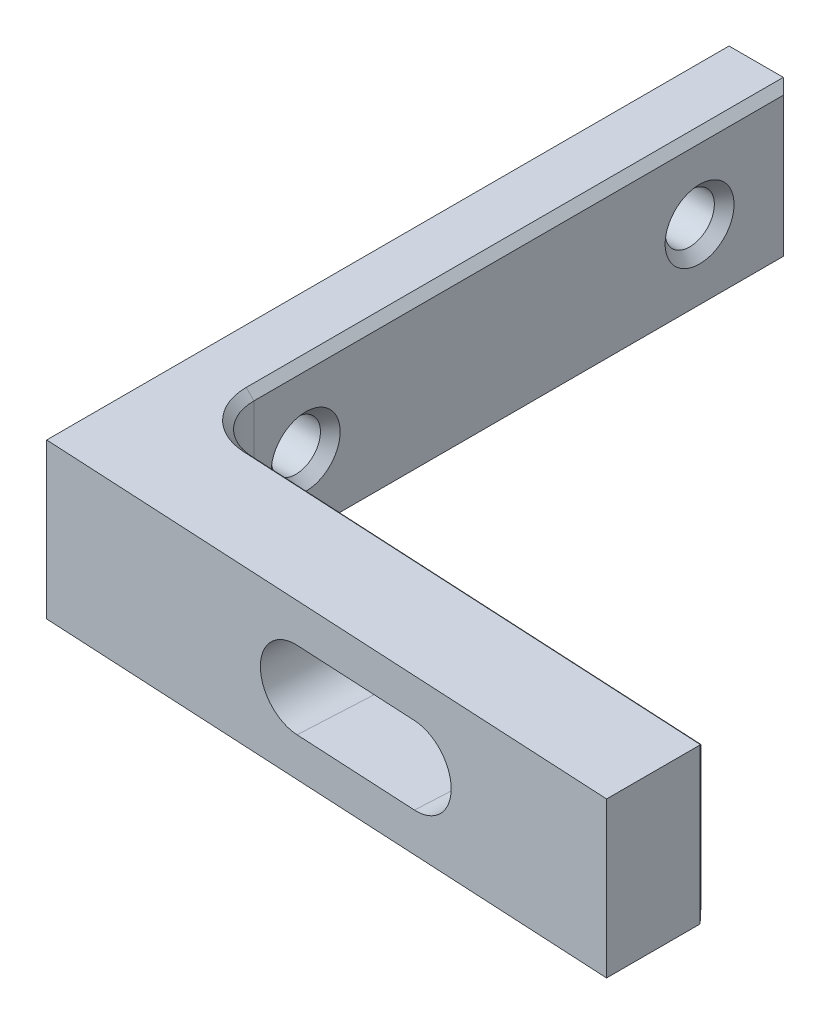
from build123d import *
from OCP.BRepFilletAPI import BRepFilletAPI_MakeChamfer

# Parameters (mm, degrees)
SKETCH1_W                             = 38.1
SKETCH1_H                             = 44
BOSS_EXTRUDE1_DEPTH                   = 10
CUT_EXTRUDE1_REACH                    = 32.772
SKETCH2_W                             = 34.1
SKETCH2_H                             = 37.65
F_1_8_0_125_DIAMETER_HOLE1_AT_2_COUNT = 2
F_1_8_0_125_DIAMETER_HOLE1_AT_2_PITCH = 25.4
DRAFT1_ANGLE                          = 3
CUT_EXTRUDE2_DEPTH                    = 33.229580472
CUT_EXTRUDE3_DEPTH                    = 45.389768844
FILLET2_R                             = 3.175
CHAMFER1_SIZE                         = 0.5
CHAMFER2_SIZE                         = 0.5
CHAMFER2_SIZE2                        = 0.528377251


with BuildPart() as part:
    # Sketch1 → Boss-Extrude1 (new body)
    with BuildSketch(Plane(origin=(0, 0, 0), x_dir=(1, 0, 0), z_dir=(0, 1, 0))):
        Rectangle(SKETCH1_W, SKETCH1_H)
    extrude(amount=BOSS_EXTRUDE1_DEPTH)

    # Sketch2 → Cut-Extrude1 (cut, up to next)
    with BuildSketch(Plane(origin=(0, 10, 0), x_dir=(1, 0, 0), z_dir=(0, 1, 0)), mode=Mode.PRIVATE) as cut_extrude1_sk1:
        with Locations((2, 3.175)):
            Rectangle(SKETCH2_W, SKETCH2_H)
    cut_extrude1_tool1 = extrude(cut_extrude1_sk1.sketch, amount=-CUT_EXTRUDE1_REACH, mode=Mode.PRIVATE) & part.part
    add(cut_extrude1_tool1.solids().sort_by_distance((2, 10, -3.175))[0], mode=Mode.SUBTRACT)

    # Sketch3 → 1/8 (0.125) Diameter Hole1 (revolve, cut)
    with BuildSketch(Plane(origin=(-19.05, 5, -16.1), x_dir=(0, 0, 1), z_dir=(0, 1, 0))):
        Polygon((0, 0), (0, 4), (2.2225, 4), (1.5875, 3.365), (1.5875, 0.635), (2.2225, 0), align=None)
    f_1_8_0_125_diameter_hole1 = revolve(axis=Axis((-25.4, 5, -16.1), (1, 0, 0)), mode=Mode.SUBTRACT)

    # 1/8 (0.125) Diameter Hole1 at 2: 1/8 (0.125) Diameter Hole1 ×2
    with Locations(*[(0, 0, i * F_1_8_0_125_DIAMETER_HOLE1_AT_2_PITCH) for i in range(1, F_1_8_0_125_DIAMETER_HOLE1_AT_2_COUNT)]):
        add(f_1_8_0_125_diameter_hole1, mode=Mode.SUBTRACT)

    # Draft1
    draft1_faces = [part.faces().sort_by_distance(p)[0] for p in [
        (0, 5, 22),
    ]]
    draft(draft1_faces, Plane(origin=(-19.05, 10, 22), x_dir=(0, 0, -1), z_dir=(-1, 0, 0)), DRAFT1_ANGLE)

    # Sketch7 → Cut-Extrude2 (cut, through all)
    with BuildSketch(Plane(origin=(0, 10, 0), x_dir=(1, 0, 0), z_dir=(0, 1, 0))):
        Polygon((-15.05, -15.65), (19.05, -15.65), (19.05, -17.437105274), align=None)
    extrude(amount=-CUT_EXTRUDE2_DEPTH, mode=Mode.SUBTRACT)

    # Sketch8 → Cut-Extrude3 (cut, through all)
    with BuildSketch(Plane(origin=(-0.859157962, 0, 16.393710517), x_dir=(-0.9986295347545739, 0, -0.05233595624294398), z_dir=(0.05233595624294399, 0, -0.998629534754574))):
        with BuildLine():
            Line((-7.189683217, 7.5), (0.810316783, 7.5))
            ThreePointArc((0.810316783, 7.5), (3.310316783, 5), (0.810316783, 2.5))
            Line((0.810316783, 2.5), (-7.189683217, 2.5))
            ThreePointArc((-7.189683217, 2.5), (-9.689683217, 5), (-7.189683217, 7.5))
        make_face()
    extrude(amount=-CUT_EXTRUDE3_DEPTH, mode=Mode.SUBTRACT)

    # Fillet2
    fillet2_edges = [part.edges().sort_by_distance(p)[0] for p in [
        (-15.05, 5, 15.65),
    ]]
    fillet(fillet2_edges, radius=FILLET2_R)

    # Chamfer1
    chamfer1_edges = [part.edges().sort_by_distance(p)[0] for p in [
        (8.817245881, 5, 16.900829354),
        (2.326153905, 2.5, 16.560645639),
        (-4.164938071, 5, 16.220461923),
        (2.326153905, 7.5, 16.560645639),
    ]]
    chamfer(chamfer1_edges, length=CHAMFER1_SIZE)

    # Chamfer2: one chamfer whose edges measure the first distance from different faces: ONE call of the kernel's chamfer builder (chamfer() names one face for all edges)
    chamfer2_edges_1 = [part.edges().sort_by_distance(p)[0] for p in [
        (-15.05, 0, -4.68148125),
        (-15.05, 5, -22),
        (-15.05, 10, -4.68148125),
        (3.504416669, 10, 16.622395774),
        (3.504416669, 0, 16.622395774),
        (-14.178063628, 10, 14.822563279),
        (-14.178063628, 0, 14.822563279),
    ]]
    chamfer2_edges_2 = [part.edges().sort_by_distance(p)[0] for p in [
        (19.05, 5, 17.437105274),
    ]]
    chamfer2_side_2 = [part.faces().sort_by_distance(p)[0] for p in [
        (9.643116423, 5, 16.944111395),
    ]]
    chamfer2 = BRepFilletAPI_MakeChamfer(part.part.solid().wrapped)
    for e in chamfer2_edges_1:
        chamfer2.Add(CHAMFER2_SIZE, e.wrapped)
    for e in chamfer2_edges_2:
        chamfer2.Add(CHAMFER2_SIZE, CHAMFER2_SIZE2, e.wrapped, chamfer2_side_2[0].wrapped)  # the first distance lies on this face
    add(Compound.cast(chamfer2.Shape()), mode=Mode.REPLACE)


solid = part.part
